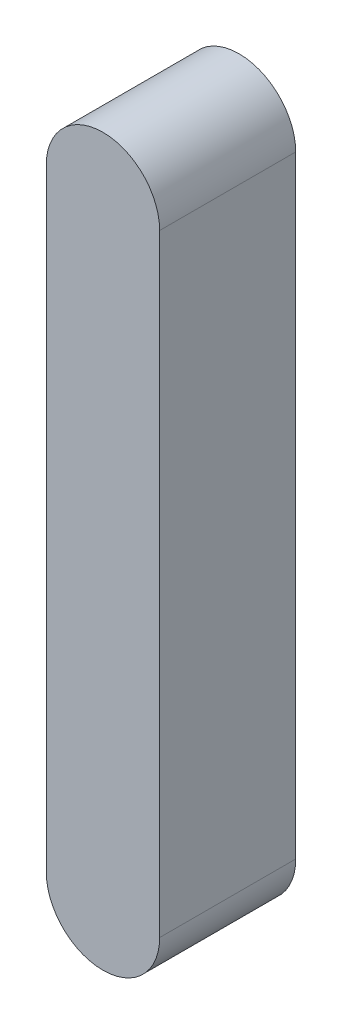
from build123d import *

# Parameters (mm, degrees)
EXTRUDE_1_DEPTH = 15


with BuildPart() as part:
    # 草图1 → 凸台-拉伸1 (new body, symmetric)
    with BuildSketch(Plane.XY):
        with BuildLine():
            Line((-12.5, 0), (-12.5, 135))
            ThreePointArc((-12.5, 135), (0, 147.5), (12.5, 135))
            Line((12.5, 135), (12.5, 0))
            ThreePointArc((12.5, 0), (0, -12.5), (-12.5, 0))
        make_face()
    extrude(amount=EXTRUDE_1_DEPTH, both=True)


solid = part.part
